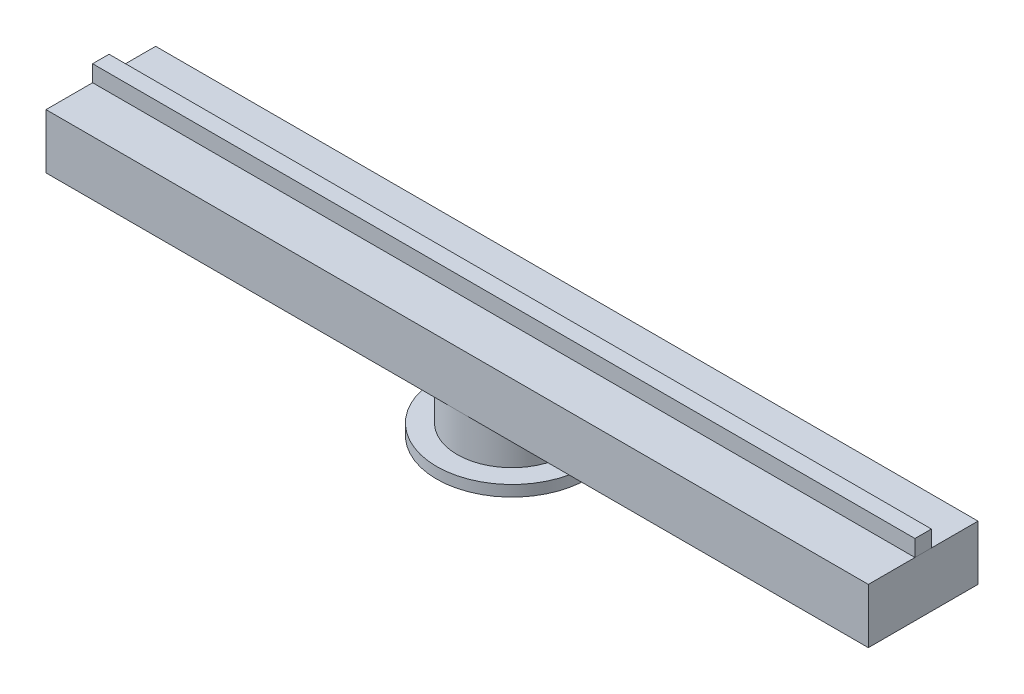
from build123d import *

# Parameters (mm, degrees)
ESBO_O1_W                = 1500
ESBO_O1_H                = 100
RESSALTO_EXTRUS_O1_DEPTH = 100
ESBO_O3_W                = 1500
ESBO_O3_H                = 30
RESSALTO_EXTRUS_O3_DEPTH = 15


with BuildPart() as part:
    # Esboço1 → Ressalto-extrusão1 (new body, symmetric)
    with BuildSketch(Plane.XY):
        with Locations((0, 50)):
            Rectangle(ESBO_O1_W, ESBO_O1_H)
    extrude(amount=RESSALTO_EXTRUS_O1_DEPTH, both=True)

    # Esboço6 → Revolução1 (revolve)
    with BuildSketch(Plane.XY):
        Polygon((0, 0), (100, 0), (100, -70), (137.5, -70), (137.5, -90), (0, -90), align=None)
    revolve(axis=Axis((0, 0, 0), (0, -1, 0)))


with BuildPart() as body_2:
    # Esboço3 → Ressalto-extrusão3 (new body, symmetric)
    with BuildSketch(Plane.XY):
        with Locations((0, 115)):
            Rectangle(ESBO_O3_W, ESBO_O3_H)
    extrude(amount=RESSALTO_EXTRUS_O3_DEPTH, both=True)


solid = Compound([part.part, body_2.part])
